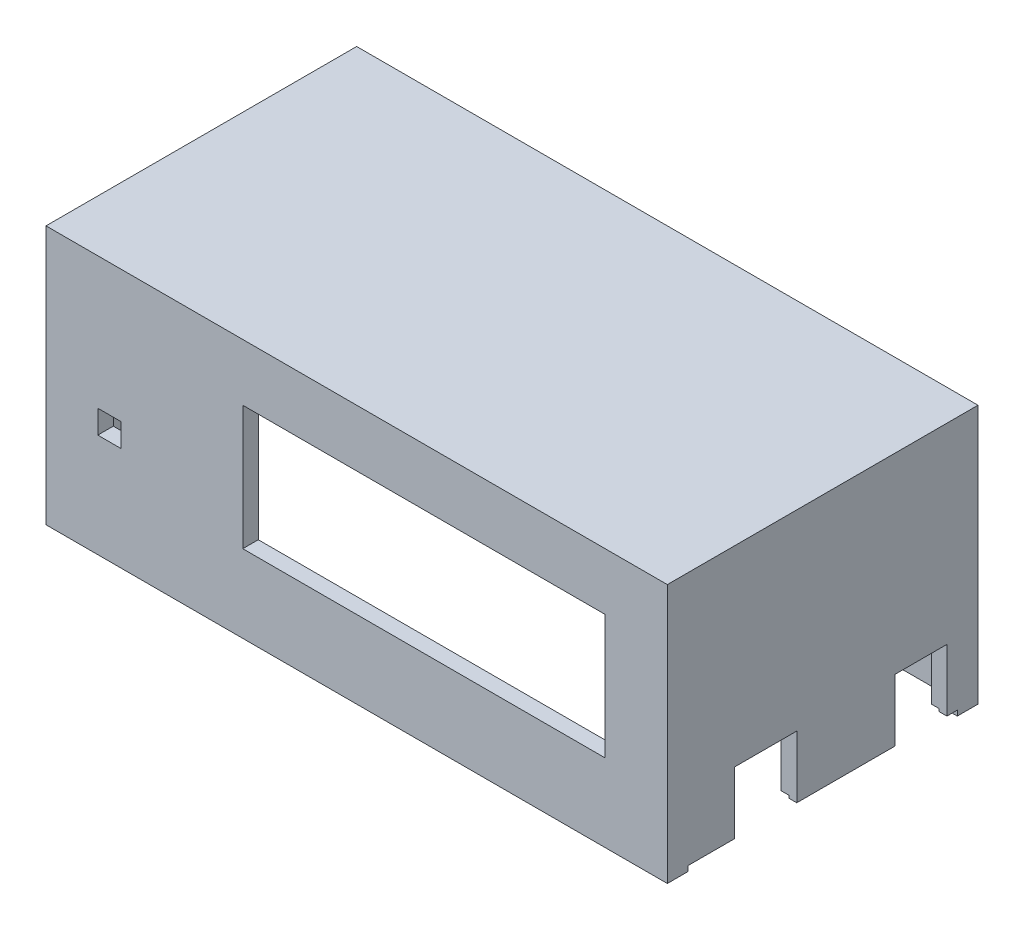
from build123d import *

# Parameters (mm, degrees)
SKETCH1_W           = 120
SKETCH1_H           = 60
BOSS_EXTRUDE1_DEPTH = 50
SKETCH2_W           = 114
SKETCH2_H           = 54
CUT_EXTRUDE1_DEPTH  = 47
SKETCH5_W           = 70
SKETCH5_H           = 24
CUT_EXTRUDE3_DEPTH  = 7
SKETCH6_W           = 4.5
SKETCH6_H           = 4.5
CUT_EXTRUDE4_DEPTH  = 7
SKETCH7_W           = 12
SKETCH7_H           = 13
SKETCH7_W_2         = 10
CUT_EXTRUDE5_DEPTH  = 3
SKETCH8_W           = 52
SKETCH8_H           = 2
CUT_EXTRUDE6_DEPTH  = 13
SKETCH9_W           = 117
SKETCH9_H           = 57
CUT_EXTRUDE7_DEPTH  = 1.5
SKETCH10_W          = 8
SKETCH10_H          = 8
CUT_EXTRUDE8_DEPTH  = 11.5


with BuildPart() as part:
    # Sketch1 → Boss-Extrude1 (new body)
    with BuildSketch(Plane(origin=(0, 0, 0), x_dir=(1, 0, 0), z_dir=(0, 1, 0))):
        Rectangle(SKETCH1_W, SKETCH1_H)
    extrude(amount=BOSS_EXTRUDE1_DEPTH)

    # Sketch2 → Cut-Extrude1 (cut)
    with BuildSketch(Plane.XZ):
        Rectangle(SKETCH2_W, SKETCH2_H)
    extrude(amount=-CUT_EXTRUDE1_DEPTH, mode=Mode.SUBTRACT)

    # Sketch5 → Cut-Extrude3 (cut)
    with BuildSketch(Plane.XY.offset(30)):
        with Locations((13, 27)):
            Rectangle(SKETCH5_W, SKETCH5_H)
    extrude(amount=-CUT_EXTRUDE3_DEPTH, mode=Mode.SUBTRACT)

    # Sketch6 → Cut-Extrude4 (cut)
    with BuildSketch(Plane.XY.offset(30)):
        with Locations((-47.75, 22.25)):
            Rectangle(SKETCH6_W, SKETCH6_H)
    extrude(amount=-CUT_EXTRUDE4_DEPTH, mode=Mode.SUBTRACT)

    # Sketch7 → Cut-Extrude5 (cut)
    with BuildSketch(Plane(origin=(60, 0, 0), x_dir=(0, 0, -1), z_dir=(1, 0, 0))):
        with Locations((-11, 6.5)):
            Rectangle(SKETCH7_W, SKETCH7_H)
        with Locations((19, 6.5)):
            Rectangle(SKETCH7_W_2, SKETCH7_H)
    extrude(amount=-CUT_EXTRUDE5_DEPTH, mode=Mode.SUBTRACT)

    # Sketch8 → Cut-Extrude6 (cut)
    with BuildSketch(Plane(origin=(60, 0, 0), x_dir=(0, 0, -1), z_dir=(1, 0, 0))):
        Rectangle(SKETCH8_W, SKETCH8_H)
    extrude(amount=-CUT_EXTRUDE6_DEPTH, mode=Mode.SUBTRACT)

    # Sketch9 → Cut-Extrude7 (cut)
    with BuildSketch(Plane.XZ):
        Rectangle(SKETCH9_W, SKETCH9_H)
    extrude(amount=-CUT_EXTRUDE7_DEPTH, mode=Mode.SUBTRACT)

    # Sketch10 → Cut-Extrude8 (cut)
    with BuildSketch(Plane(origin=(0, 0, -30), x_dir=(-1, 0, 0), z_dir=(0, 0, -1))):
        with Locations((0, 12)):
            Rectangle(SKETCH10_W, SKETCH10_H)
    extrude(amount=-CUT_EXTRUDE8_DEPTH, mode=Mode.SUBTRACT)


solid = part.part
